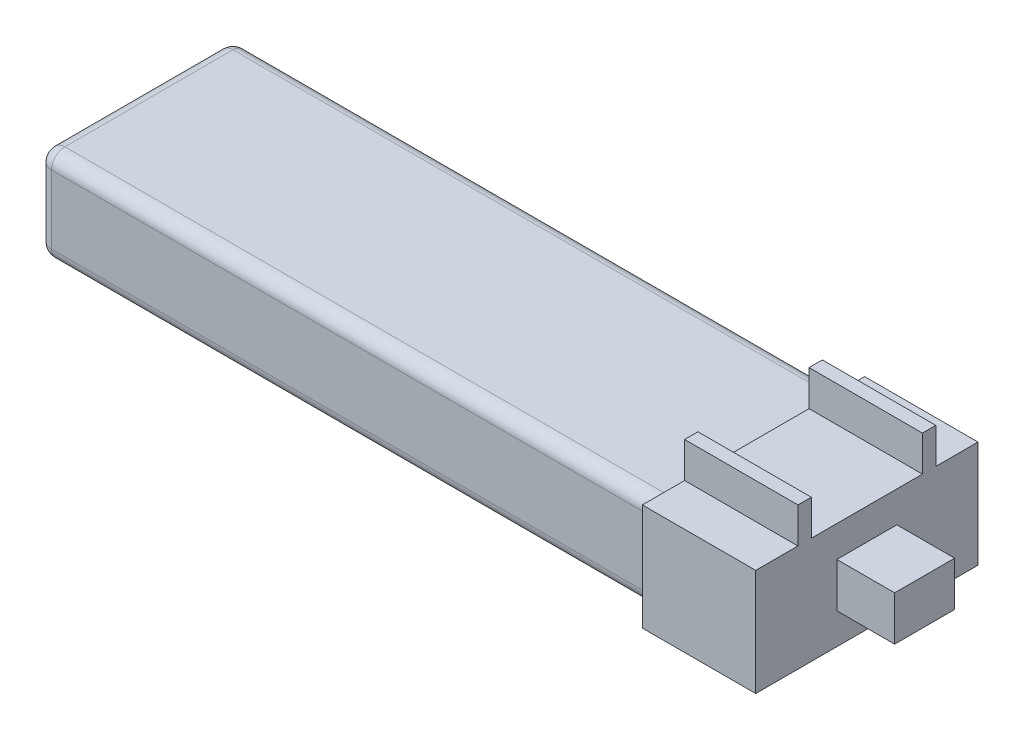
from build123d import *

# Parameters (mm, degrees)
SKETCH1_W           = 41.91
SKETCH1_H           = 12.7
BOSS_EXTRUDE1_DEPTH = 3.048
SKETCH2_W           = 0.762
SKETCH2_H           = 2.032
BOSS_EXTRUDE2_DEPTH = 6.604
SKETCH2_3_W         = 3.429
SKETCH2_3_H         = 1.27
BOSS_EXTRUDE3_DEPTH = 3.175
CUT_EXTRUDE1_START  = -6.604
SKETCH4_W           = 14.239901434
SKETCH4_H           = 7.9172944
SKETCH4_W_2         = 11.1252
SKETCH4_H_2         = 5.4356
CUT_EXTRUDE1_DEPTH  = 36.306
FILLET1_R           = 0.762
CUT_EXTRUDE2_DEPTH  = 0.127
SKETCH6_W           = 3.429
SKETCH6_H           = 2.54
BOSS_EXTRUDE4_DEPTH = 0.127


with BuildPart() as part:
    # Sketch1 → Boss-Extrude1 (new body, symmetric)
    with BuildSketch(Plane(origin=(0, 0, 0), x_dir=(1, 0, 0), z_dir=(0, 1, 0))):
        Rectangle(SKETCH1_W, SKETCH1_H)
    extrude(amount=BOSS_EXTRUDE1_DEPTH, both=True)

    # Sketch2 → Boss-Extrude2 (add)
    with BuildSketch(Plane(origin=(20.955, 0, 0), x_dir=(0, 0, -1), z_dir=(1, 0, 0))):
        with Locations((-3.556, 4.064)):
            Rectangle(SKETCH2_W, SKETCH2_H)
        with Locations((3.556, 4.064)):
            Rectangle(SKETCH2_W, SKETCH2_H)
    extrude(amount=-BOSS_EXTRUDE2_DEPTH)

    # Sketch2_3 → Boss-Extrude3 (add)
    with BuildSketch(Plane(origin=(20.955, 0, 0), x_dir=(0, 0, -1), z_dir=(1, 0, 0))):
        with Locations((0, 0.635)):
            Rectangle(SKETCH2_3_W, SKETCH2_3_H)
        with Locations((0, -0.635)):
            Rectangle(SKETCH2_3_W, SKETCH2_3_H)
    extrude(amount=BOSS_EXTRUDE3_DEPTH)

    # Sketch4 → Cut-Extrude1 (cut, through all)
    with BuildSketch(Plane(origin=(20.955, 0, 0), x_dir=(0, 0, -1), z_dir=(1, 0, 0)).offset(CUT_EXTRUDE1_START)):
        Rectangle(SKETCH4_W, SKETCH4_H)
        Rectangle(SKETCH4_W_2, SKETCH4_H_2, mode=Mode.SUBTRACT)
    extrude(amount=-CUT_EXTRUDE1_DEPTH, mode=Mode.SUBTRACT)

    # Fillet1
    fillet1_edges = [part.edges().sort_by_distance(p)[0] for p in [
        (-20.955, 0, 5.5626),
        (-20.955, -2.7178, 0),
        (-20.955, 0, -5.5626),
        (-20.955, 2.7178, 0),
        (-3.302, -2.7178, 5.5626),
        (-3.302, 2.7178, 5.5626),
        (-3.302, 2.7178, -5.5626),
        (-3.302, -2.7178, -5.5626),
    ]]
    fillet(fillet1_edges, radius=FILLET1_R)

    # Sketch5 → Cut-Extrude2 (cut)
    with BuildSketch(Plane(origin=(20.955, 0, 0), x_dir=(0, 0, -1), z_dir=(1, 0, 0))):
        Polygon((-6.35, -3.048), (6.35, -3.048), (6.35, 3.048), (3.937, 3.048), (3.937, 5.08), (3.175, 5.08), (3.175, 3.048), (-3.175, 3.048), (-3.175, 5.08), (-3.937, 5.08), (-3.937, 3.048), (-6.35, 3.048), align=None)
    extrude(amount=-CUT_EXTRUDE2_DEPTH, mode=Mode.SUBTRACT)

    # Sketch6 → Boss-Extrude4 (add)
    with BuildSketch(Plane.ZY.offset(-20.955)):
        Rectangle(SKETCH6_W, SKETCH6_H)
    extrude(amount=BOSS_EXTRUDE4_DEPTH)


solid = part.part
